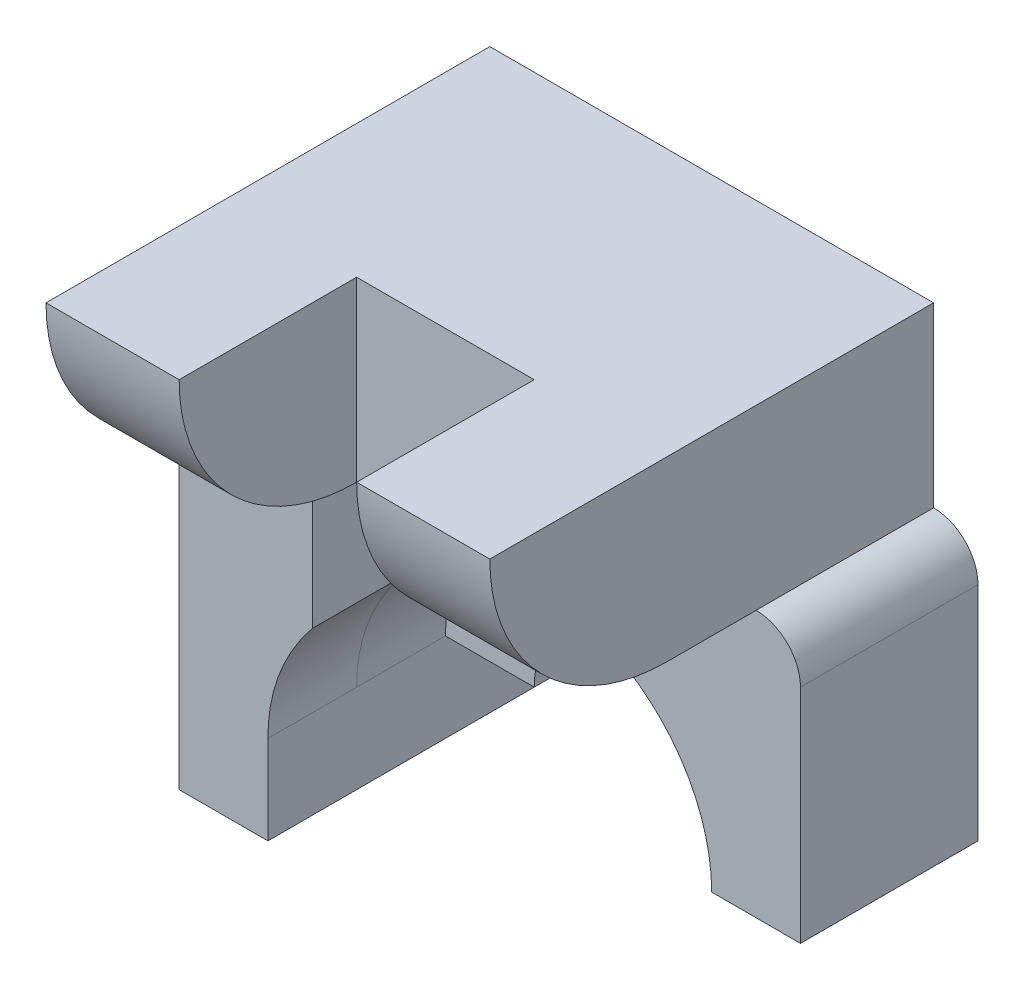
from build123d import *

# Parameters (mm, degrees)
BOSS_EXTRUDE1_DEPTH = 10
BOSS_EXTRUDE2_DEPTH = 5
BOSS_EXTRUDE6_DEPTH = 5
SKETCH10_W          = 25
SKETCH10_H          = 10
BOSS_EXTRUDE7_DEPTH = 25
CUT_EXTRUDE4_DEPTH  = 28.5000001
SKETCH12_W          = 10
SKETCH12_H          = 10
CUT_EXTRUDE5_DEPTH  = 25


with BuildPart() as part:
    # Sketch1 → Boss-Extrude1 (new body)
    with BuildSketch(Plane.XY):
        with BuildLine():
            Line((10, 0), (15, 0))
            Line((15, 0), (15, 12.5))
            ThreePointArc((15, 12.5), (14.267766953, 14.267766953), (12.5, 15))
            Line((12.5, 15), (-12.5, 15))
            ThreePointArc((-12.5, 15), (-14.267766953, 14.267766953), (-15, 12.5))
            Line((-15, 12.5), (-15, -5))
            Line((-15, -5), (-10, -5))
            Line((-10, -5), (-10, 0))
            ThreePointArc((-10, 0), (0, 10), (10, 0))
        make_face()
    extrude(amount=BOSS_EXTRUDE1_DEPTH)

    # Sketch2 → Boss-Extrude2 (add)
    with BuildSketch(Plane.XY):
        with BuildLine():
            ThreePointArc((-10, 0), (0, 10), (10, 0))
            Line((10, 0), (5, 0))
            ThreePointArc((5, 0), (0, 5), (-5, 0))
            Line((-5, 0), (-10, 0))
        make_face()
    extrude(amount=BOSS_EXTRUDE2_DEPTH)

    # Sketch9 → Boss-Extrude6 (add)
    with BuildSketch(Plane.XY.offset(10)):
        with BuildLine():
            Line((-15, 12.5), (-15, -5))
            Line((-15, -5), (-10, -5))
            Line((-10, -5), (-10, 0))
            add(Edge.make_bspline(
                [(-7.5, 6.614378278), (-10, 3.535533906), (-10, 0)],
                knots=[0, 0, 0, 1, 1, 1], degree=2))
            Line((-7.5, 6.614378278), (-7.5, 15))
            Line((-7.5, 15), (-12.5, 15))
            ThreePointArc((-12.5, 15), (-14.267766953, 14.267766953), (-15, 12.5))
        make_face()
    extrude(amount=BOSS_EXTRUDE6_DEPTH)

    # Sketch10 → Boss-Extrude7 (add)
    with BuildSketch(Plane.XY):
        with Locations((0, 20)):
            Rectangle(SKETCH10_W, SKETCH10_H)
    extrude(amount=BOSS_EXTRUDE7_DEPTH)

    # Sketch11 → Cut-Extrude4 (cut, through all)
    with BuildSketch(Plane(origin=(12.5, 0, 0), x_dir=(0, 0, -1), z_dir=(1, 0, 0))):
        with BuildLine():
            Line((-25, 25), (-25, 15))
            Line((-25, 15), (-15, 15))
            ThreePointArc((-15, 15), (-22.071067812, 17.928932188), (-25, 25))
        make_face()
    extrude(amount=-CUT_EXTRUDE4_DEPTH, mode=Mode.SUBTRACT)

    # Sketch12 → Cut-Extrude5 (cut)
    with BuildSketch(Plane(origin=(0, 25, 0), x_dir=(1, 0, 0), z_dir=(0, 1, 0))):
        with Locations((0, -20)):
            Rectangle(SKETCH12_W, SKETCH12_H)
    extrude(amount=-CUT_EXTRUDE5_DEPTH, mode=Mode.SUBTRACT)


solid = part.part
